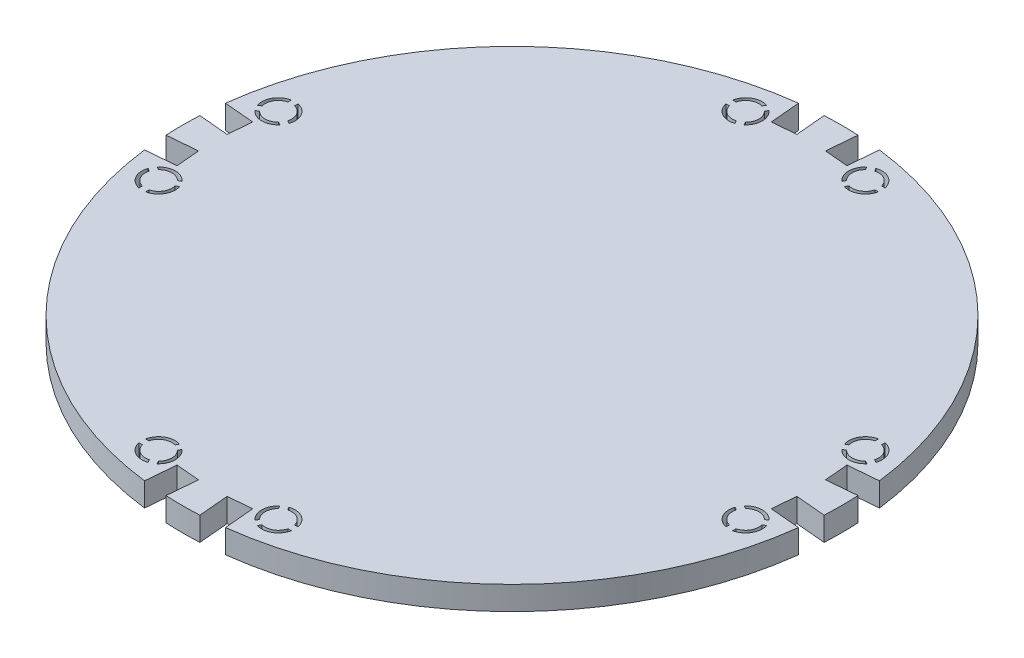
from build123d import *

# Parameters (mm, degrees)
SKETCH2_R                = 62.865
BOSS_EXTRUDE1_DEPTH      = 2.25171
CUT_EXTRUDE1_DEPTH       = 4.50342
CIRPATTERN1_COUNT        = 4
CUT_EXTRUDE3_DEPTH       = 5.50342
CIRPATTERN2_COUNT        = 4
CIRPATTERN2_COPY_1_DEPTH = 5.50342
CIRPATTERN2_COPY_2_DEPTH = 5.50342
CIRPATTERN2_COPY_3_DEPTH = 5.50342


with BuildPart() as part:
    # Sketch2 → Boss-Extrude1 (new body, symmetric)
    with BuildSketch(Plane(origin=(0, 0, 0), x_dir=(1, 0, 0), z_dir=(0, 1, 0))):
        Circle(SKETCH2_R)
    extrude(amount=BOSS_EXTRUDE1_DEPTH, both=True)

    # Sketch3 → Cut-Extrude1 (cut)
    with BuildSketch(Plane(origin=(0, 2.25171, 0), x_dir=(1, 0, 0), z_dir=(0, 1, 0))):
        with BuildLine():
            ThreePointArc((-62.389344719, 7.718671554), (-62.517592036, 6.5999175), (-62.625779696, 5.479045768))
            Line((-62.625779696, 5.479045768), (-56.879689804, 4.976328043))
            Line((-56.879689804, 4.976328043), (-56.683440347, 7.219469606))
            Line((-56.683440347, 7.219469606), (-62.389344719, 7.718671554))
        make_face()
        with BuildLine():
            Line((-56.879689804, 4.976328043), (-62.625779696, 5.479045768))
            ThreePointArc((-62.625779696, 5.479045768), (-62.713872983, 4.356416006), (-62.781843634, 3.232388427))
            Line((-62.781843634, 3.232388427), (-57.075939262, 2.733186479))
            Line((-57.075939262, 2.733186479), (-56.879689804, 4.976328043))
        make_face()
        with BuildLine():
            ThreePointArc((-5.479045768, 62.625779696), (-6.5999175, 62.517592036), (-7.718671554, 62.389344719))
            Line((-7.718671554, 62.389344719), (-7.219469606, 56.683440347))
            Line((-7.219469606, 56.683440347), (-4.976328043, 56.879689804))
            Line((-4.976328043, 56.879689804), (-5.479045768, 62.625779696))
        make_face()
        with BuildLine():
            Line((-5.479045768, 62.625779696), (-4.976328043, 56.879689804))
            Line((-4.976328043, 56.879689804), (-2.733186479, 57.075939262))
            Line((-2.733186479, 57.075939262), (-3.232388427, 62.781843634))
            ThreePointArc((-3.232388427, 62.781843634), (-4.356416006, 62.713872983), (-5.479045768, 62.625779696))
        make_face()
    cut_extrude1 = extrude(amount=-CUT_EXTRUDE1_DEPTH, mode=Mode.SUBTRACT)

    # CirPattern1: Cut-Extrude1 ×4 about axis
    cirpattern1_axis = Axis((0, 0, 0), (0, 1, 0))
    for i in range(1, CIRPATTERN1_COUNT):
        add(cut_extrude1.rotate(cirpattern1_axis, i * 360 / CIRPATTERN1_COUNT), mode=Mode.SUBTRACT)

    # Sketch5 → Cut-Extrude3 (cut, through all)
    with BuildSketch(Plane(origin=(0, 2.25171, 0), x_dir=(1, 0, 0), z_dir=(0, 1, 0))):
        with BuildLine():
            ThreePointArc((-53.618758684, -9.324647882), (-55.99533552, -8.255), (-58.371912356, -9.324647882))
            Line((-58.371912356, -9.324647882), (-57.807690269, -9.650401656))
            ThreePointArc((-57.807690269, -9.650401656), (-55.99533552, -8.89), (-54.182980771, -9.650401656))
            Line((-54.182980771, -9.650401656), (-53.618758684, -9.324647882))
        make_face()
        with BuildLine():
            Line((-58.442690269, -10.750253919), (-59.006912356, -10.424500145))
            ThreePointArc((-59.006912356, -10.424500145), (-58.744966177, -13.0175), (-56.63033552, -14.540851973))
            Line((-56.63033552, -14.540851973), (-56.63033552, -13.889344425))
            ThreePointArc((-56.63033552, -13.889344425), (-58.195040046, -12.7), (-58.442690269, -10.750253919))
        make_face()
        with BuildLine():
            Line((-52.983758684, -10.424500145), (-53.547980771, -10.750253919))
            ThreePointArc((-53.547980771, -10.750253919), (-53.478603407, -11.086984739), (-53.45533552, -11.43))
            ThreePointArc((-53.45533552, -11.43), (-53.987289206, -12.985425987), (-55.36033552, -13.889344425))
            Line((-55.36033552, -13.889344425), (-55.36033552, -14.540851973))
            ThreePointArc((-55.36033552, -14.540851973), (-53.535991095, -13.438046314), (-52.82033552, -11.43))
            ThreePointArc((-52.82033552, -11.43), (-52.861457614, -10.920653092), (-52.983758684, -10.424500145))
        make_face()
    cut_extrude3 = extrude(amount=-CUT_EXTRUDE3_DEPTH, mode=Mode.SUBTRACT)

    # Mirror1: Cut-Extrude3 across plane
    add(cut_extrude3.mirror(Plane.XY), mode=Mode.SUBTRACT)

    # CirPattern2: Cut-Extrude3 ×4 about axis
    cirpattern2_axis = Axis((0, 0, 0), (0, 1, 0))
    for i in range(1, CIRPATTERN2_COUNT):
        add(cut_extrude3.rotate(cirpattern2_axis, i * 360 / CIRPATTERN2_COUNT), mode=Mode.SUBTRACT)

    # CirPattern2 copy 1 sketch → CirPattern2 copy 1 (cut, through all)
    with BuildSketch(Plane(origin=(0, 2.25171, 0), x_dir=(0, 0, -1), z_dir=(0, 1, 0))):
        with BuildLine():
            ThreePointArc((-53.618758684, 9.324647882), (-55.99533552, 8.255), (-58.371912356, 9.324647882))
            Line((-58.371912356, 9.324647882), (-57.807690269, 9.650401656))
            ThreePointArc((-57.807690269, 9.650401656), (-55.99533552, 8.89), (-54.182980771, 9.650401656))
            Line((-54.182980771, 9.650401656), (-53.618758684, 9.324647882))
        make_face()
        with BuildLine():
            Line((-58.442690269, 10.750253919), (-59.006912356, 10.424500145))
            ThreePointArc((-59.006912356, 10.424500145), (-58.744966177, 13.0175), (-56.63033552, 14.540851973))
            Line((-56.63033552, 14.540851973), (-56.63033552, 13.889344425))
            ThreePointArc((-56.63033552, 13.889344425), (-58.195040046, 12.7), (-58.442690269, 10.750253919))
        make_face()
        with BuildLine():
            Line((-52.983758684, 10.424500145), (-53.547980771, 10.750253919))
            ThreePointArc((-53.547980771, 10.750253919), (-53.478603407, 11.086984739), (-53.45533552, 11.43))
            ThreePointArc((-53.45533552, 11.43), (-53.987289206, 12.985425987), (-55.36033552, 13.889344425))
            Line((-55.36033552, 13.889344425), (-55.36033552, 14.540851973))
            ThreePointArc((-55.36033552, 14.540851973), (-53.535991095, 13.438046314), (-52.82033552, 11.43))
            ThreePointArc((-52.82033552, 11.43), (-52.861457614, 10.920653092), (-52.983758684, 10.424500145))
        make_face()
    extrude(amount=-CIRPATTERN2_COPY_1_DEPTH, mode=Mode.SUBTRACT)

    # CirPattern2 copy 2 sketch → CirPattern2 copy 2 (cut, through all)
    with BuildSketch(Plane(origin=(0, 2.25171, 0), x_dir=(-1, 0, 0), z_dir=(0, 1, 0))):
        with BuildLine():
            ThreePointArc((-53.618758684, 9.324647882), (-55.99533552, 8.255), (-58.371912356, 9.324647882))
            Line((-58.371912356, 9.324647882), (-57.807690269, 9.650401656))
            ThreePointArc((-57.807690269, 9.650401656), (-55.99533552, 8.89), (-54.182980771, 9.650401656))
            Line((-54.182980771, 9.650401656), (-53.618758684, 9.324647882))
        make_face()
        with BuildLine():
            Line((-58.442690269, 10.750253919), (-59.006912356, 10.424500145))
            ThreePointArc((-59.006912356, 10.424500145), (-58.744966177, 13.0175), (-56.63033552, 14.540851973))
            Line((-56.63033552, 14.540851973), (-56.63033552, 13.889344425))
            ThreePointArc((-56.63033552, 13.889344425), (-58.195040046, 12.7), (-58.442690269, 10.750253919))
        make_face()
        with BuildLine():
            Line((-52.983758684, 10.424500145), (-53.547980771, 10.750253919))
            ThreePointArc((-53.547980771, 10.750253919), (-53.478603407, 11.086984739), (-53.45533552, 11.43))
            ThreePointArc((-53.45533552, 11.43), (-53.987289206, 12.985425987), (-55.36033552, 13.889344425))
            Line((-55.36033552, 13.889344425), (-55.36033552, 14.540851973))
            ThreePointArc((-55.36033552, 14.540851973), (-53.535991095, 13.438046314), (-52.82033552, 11.43))
            ThreePointArc((-52.82033552, 11.43), (-52.861457614, 10.920653092), (-52.983758684, 10.424500145))
        make_face()
    extrude(amount=-CIRPATTERN2_COPY_2_DEPTH, mode=Mode.SUBTRACT)

    # CirPattern2 copy 3 sketch → CirPattern2 copy 3 (cut, through all)
    with BuildSketch(Plane.ZX.offset(2.25171)):
        with BuildLine():
            ThreePointArc((-53.618758684, 9.324647882), (-55.99533552, 8.255), (-58.371912356, 9.324647882))
            Line((-58.371912356, 9.324647882), (-57.807690269, 9.650401656))
            ThreePointArc((-57.807690269, 9.650401656), (-55.99533552, 8.89), (-54.182980771, 9.650401656))
            Line((-54.182980771, 9.650401656), (-53.618758684, 9.324647882))
        make_face()
        with BuildLine():
            Line((-58.442690269, 10.750253919), (-59.006912356, 10.424500145))
            ThreePointArc((-59.006912356, 10.424500145), (-58.744966177, 13.0175), (-56.63033552, 14.540851973))
            Line((-56.63033552, 14.540851973), (-56.63033552, 13.889344425))
            ThreePointArc((-56.63033552, 13.889344425), (-58.195040046, 12.7), (-58.442690269, 10.750253919))
        make_face()
        with BuildLine():
            Line((-52.983758684, 10.424500145), (-53.547980771, 10.750253919))
            ThreePointArc((-53.547980771, 10.750253919), (-53.478603407, 11.086984739), (-53.45533552, 11.43))
            ThreePointArc((-53.45533552, 11.43), (-53.987289206, 12.985425987), (-55.36033552, 13.889344425))
            Line((-55.36033552, 13.889344425), (-55.36033552, 14.540851973))
            ThreePointArc((-55.36033552, 14.540851973), (-53.535991095, 13.438046314), (-52.82033552, 11.43))
            ThreePointArc((-52.82033552, 11.43), (-52.861457614, 10.920653092), (-52.983758684, 10.424500145))
        make_face()
    extrude(amount=-CIRPATTERN2_COPY_3_DEPTH, mode=Mode.SUBTRACT)


solid = part.part
